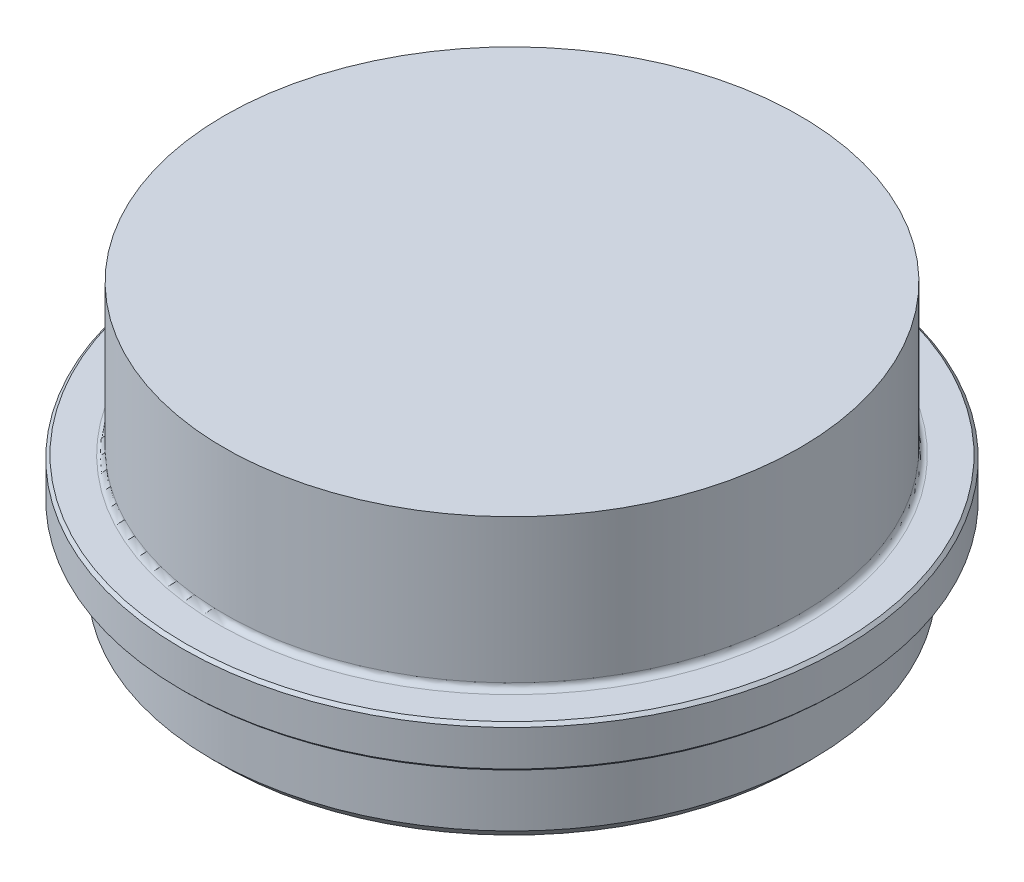
from build123d import *

# Parameters (mm, degrees)
CHAMFER1_SIZE      = 1
CHAMFER2_SIZE      = 0.25
FILLET1_R          = 0.5
SKETCH2_R          = 2.5
SKETCH2_R_2        = 3
CUT_EXTRUDE1_DEPTH = 14


with BuildPart() as part:
    # Sketch1 → Revolve1 (revolve)
    with BuildSketch(Plane.XY):
        Polygon((27.5, -12.5), (27.5, -16), (25, -16), (25, -23), (12.4, -23), (12.4, -16), (11.5, -16), (11.5, -5), (0, -5), (0, 0), (24, 0), (24, -12.5), align=None)
    revolve(axis=Axis((0, -394.340972919, 0), (0, 1, 0)))

    # Chamfer1
    chamfer1_edges = [part.edges().sort_by_distance(p)[0] for p in [
        (-12.4, -23, 0),
        (-25, -23, 0),
    ]]
    chamfer(chamfer1_edges, length=CHAMFER1_SIZE)

    # Chamfer2
    chamfer2_edges = [part.edges().sort_by_distance(p)[0] for p in [
        (-11.5, -16, 0),
        (-27.5, -12.5, 0),
        (-27.5, -16, 0),
    ]]
    chamfer(chamfer2_edges, length=CHAMFER2_SIZE)

    # Fillet1
    fillet1_edges = [part.edges().sort_by_distance(p)[0] for p in [
        (-11.5, -5, 0),
        (-24, -12.5, 0),
    ]]
    fillet(fillet1_edges, radius=FILLET1_R)

    # Sketch2 → Cut-Extrude1 (cut)
    with BuildSketch(Plane.XZ.offset(23)):
        with Locations((14.142135624, 14.142135624)):
            Circle(SKETCH2_R)
        with Locations((-14.142135624, 14.142135624)):
            Circle(SKETCH2_R)
        with Locations((14.142135624, -14.142135624)):
            Circle(SKETCH2_R)
        with Locations((-14.142135624, -14.142135624)):
            Circle(SKETCH2_R)
        with Locations((0, 20)):
            Circle(SKETCH2_R_2)
    extrude(amount=-CUT_EXTRUDE1_DEPTH, mode=Mode.SUBTRACT)


solid = part.part
